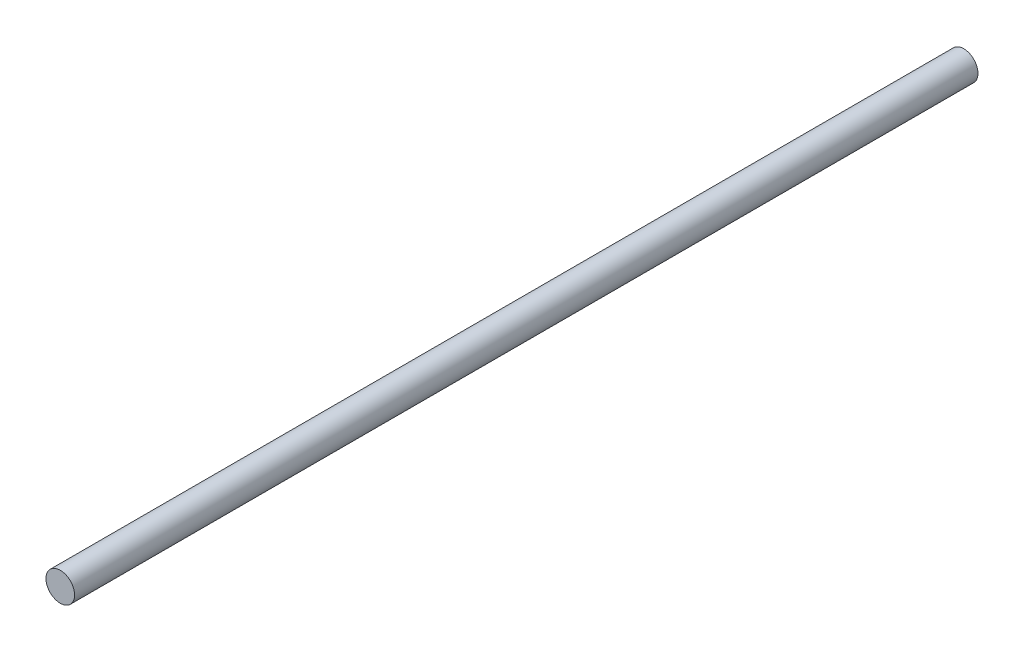
from build123d import *

# Parameters (mm, degrees)
SKETCH1_R           = 2.413
BOSS_EXTRUDE1_DEPTH = 152.4


with BuildPart() as part:
    # Sketch1 → Boss-Extrude1 (new body)
    with BuildSketch(Plane.XY):
        Circle(SKETCH1_R)
    extrude(amount=BOSS_EXTRUDE1_DEPTH)


solid = part.part
